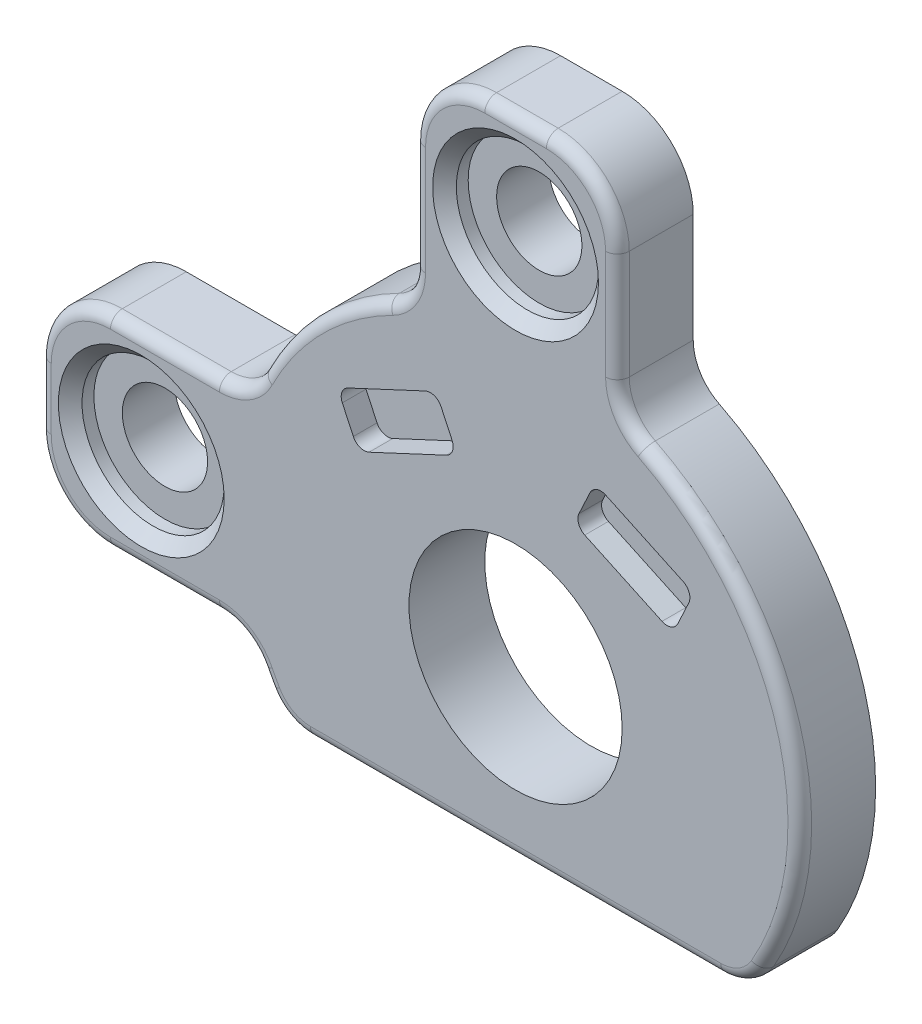
from build123d import *

# Parameters (mm, degrees)
SKETCH10_R          = 4.5
BOSS_EXTRUDE6_DEPTH = 1.6
SKETCH13_R          = 1.8
BOSS_EXTRUDE7_DEPTH = 1.6
FILLET1_R           = 2
CUT_EXTRUDE2_DEPTH  = 1
SKETCH16_R          = 3
CUT_EXTRUDE3_DEPTH  = 1
CHAMFER1_SIZE       = 0.5
FILLET2_R           = 0.5


with BuildPart() as part:
    # Sketch10 → Boss-Extrude6 (new body, symmetric)
    with BuildSketch(Plane.XY):
        with BuildLine():
            Line((-9.746794345, -7), (9.746794345, -7))
            ThreePointArc((9.746794345, -7), (0, 12), (-9.746794345, -7))
        make_face()
        Circle(SKETCH10_R, mode=Mode.SUBTRACT)
    extrude(amount=BOSS_EXTRUDE6_DEPTH, both=True)

    # Sketch13 → Boss-Extrude7 (add, symmetric)
    with BuildSketch(Plane.XY):
        with BuildLine():
            Line((-11.203124564, 4.3), (-17.1, 4.3))
            ThreePointArc((-17.1, 4.3), (-19.221320344, 3.421320344), (-20.1, 1.3))
            Line((-20.1, 1.3), (-20.1, -1.3))
            ThreePointArc((-20.1, -1.3), (-19.221320344, -3.421320344), (-17.1, -4.3))
            Line((-17.1, -4.3), (-11.203124564, -4.3))
            ThreePointArc((-11.203124564, -4.3), (-12, 0), (-11.203124564, 4.3))
        make_face()
        with Locations((-15.8, 0)):
            Circle(SKETCH13_R, mode=Mode.SUBTRACT)
        with BuildLine():
            Line((4.3, 11.203124564), (4.3, 17.1))
            ThreePointArc((4.3, 17.1), (3.421320344, 19.221320344), (1.3, 20.1))
            Line((1.3, 20.1), (-1.3, 20.1))
            ThreePointArc((-1.3, 20.1), (-3.421320344, 19.221320344), (-4.3, 17.1))
            Line((-4.3, 17.1), (-4.3, 11.203124564))
            ThreePointArc((-4.3, 11.203124564), (0, 12), (4.3, 11.203124564))
        make_face()
        with Locations((0, 15.8)):
            Circle(SKETCH13_R, mode=Mode.SUBTRACT)
    extrude(amount=BOSS_EXTRUDE7_DEPTH, both=True)

    # Fillet1
    fillet1_edges = [part.edges().sort_by_distance(p)[0] for p in [
        (-11.203124564, -4.3, 0),
        (-11.203124564, 4.3, 0),
        (-4.3, 11.203124564, 0),
        (4.3, 11.203124564, 0),
        (9.746794345, -7, 0),
        (-9.746794345, -7, 0),
    ]]
    fillet(fillet1_edges, radius=FILLET1_R)

    # Sketch15 → Cut-Extrude2 (cut)
    with BuildSketch(Plane(origin=(0, 0, 1.6), x_dir=(-1, 0, 0), z_dir=(0, 0, -1))):
        with BuildLine():
            Line((-3.808047036, 8.187368684), (-7.070755069, 6.665942941))
            ThreePointArc((-7.070755069, 6.665942941), (-7.329292249, 6.38379912), (-7.312599832, 6.001479917))
            Line((-7.312599832, 6.001479917), (-6.847719744, 5.004541351))
            ThreePointArc((-6.847719744, 5.004541351), (-6.565575922, 4.746004172), (-6.18325672, 4.762696589))
            Line((-6.18325672, 4.762696589), (-2.920548686, 6.284122331))
            ThreePointArc((-2.920548686, 6.284122331), (-2.662011507, 6.566266153), (-2.678703924, 6.948585355))
            Line((-2.678703924, 6.948585355), (-3.143584012, 7.945523921))
            ThreePointArc((-3.143584012, 7.945523921), (-3.425727833, 8.204061101), (-3.808047036, 8.187368684))
        make_face()
        with BuildLine():
            Line((6.847719744, 5.004541351), (7.312599832, 6.001479917))
            ThreePointArc((7.312599832, 6.001479917), (7.329292249, 6.38379912), (7.070755069, 6.665942941))
            Line((7.070755069, 6.665942941), (3.808047036, 8.187368684))
            ThreePointArc((3.808047036, 8.187368684), (3.425727833, 8.204061101), (3.143584012, 7.945523921))
            Line((3.143584012, 7.945523921), (2.678703924, 6.948585355))
            ThreePointArc((2.678703924, 6.948585355), (2.662011507, 6.566266153), (2.920548686, 6.284122331))
            Line((2.920548686, 6.284122331), (6.18325672, 4.762696589))
            ThreePointArc((6.18325672, 4.762696589), (6.565575922, 4.746004172), (6.847719744, 5.004541351))
        make_face()
    extrude(amount=CUT_EXTRUDE2_DEPTH, mode=Mode.SUBTRACT)

    # Sketch16 → Cut-Extrude3 (cut)
    with BuildSketch(Plane(origin=(0, 0, 1.6), x_dir=(-1, 0, 0), z_dir=(0, 0, -1))):
        with Locations((0, 15.8)):
            Circle(SKETCH16_R)
        with Locations((15.8, 0)):
            Circle(SKETCH16_R)
    extrude(amount=CUT_EXTRUDE3_DEPTH, mode=Mode.SUBTRACT)

    # Chamfer1
    chamfer1_edges = [part.edges().sort_by_distance(p)[0] for p in [
        (3, 15.8, 1.6),
        (-12.8, 0, 1.6),
    ]]
    chamfer(chamfer1_edges, length=CHAMFER1_SIZE)

    # Fillet2
    fillet2_edges = [part.edges().sort_by_distance(p)[0] for p in [
        (-19.221320344, 3.421320344, 1.6),
        (-20.1, 0, 1.6),
        (-19.221320344, -3.421320344, 1.6),
        (-14.801199885, -4.3, 1.6),
        (3.421320344, 19.221320344, 1.6),
        (0, 20.1, 1.6),
        (-3.421320344, 19.221320344, 1.6),
        (-4.3, 14.801199885, 1.6),
        (-14.801199885, 4.3, 1.6),
        (-8.485281374, 8.485281374, 1.6),
        (4.3, 14.801199885, 1.6),
        (11.498184685, 3.433911609, 1.6),
        (-10.558586547, -5.702302178, 1.6),
        (0, -7, 1.6),
        (-9.660254038, -6.732050808, 1.6),
        (9.660254038, -6.732050808, 1.6),
        (-11.453590921, 4.597061363, 1.6),
        (4.597061363, 11.453590921, 1.6),
        (-4.597061363, 11.453590921, 1.6),
        (-11.453590921, -4.597061363, 1.6),
    ]]
    fillet(fillet2_edges, radius=FILLET2_R)


solid = part.part
